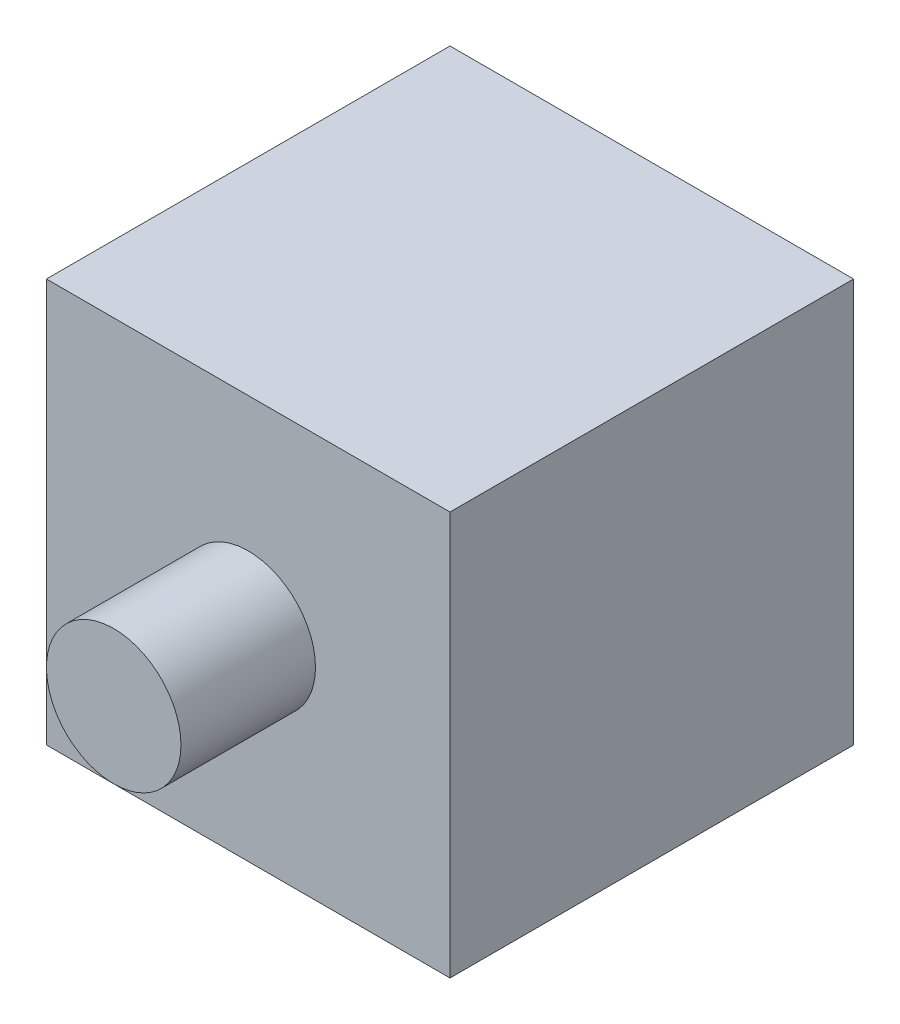
from build123d import *

# Parameters (mm, degrees)
SKETCH1_W           = 30
SKETCH1_H           = 30
BOSS_EXTRUDE1_DEPTH = 30
SKETCH2_R           = 5
BOSS_EXTRUDE2_DEPTH = 10


with BuildPart() as part:
    # Sketch1 → Boss-Extrude1 (new body)
    with BuildSketch(Plane(origin=(0, 0, 0), x_dir=(1, 0, 0), z_dir=(0, 1, 0))):
        Rectangle(SKETCH1_W, SKETCH1_H)
    extrude(amount=BOSS_EXTRUDE1_DEPTH)

    # Sketch2 → Boss-Extrude2 (add)
    with BuildSketch(Plane.XY.offset(15)):
        with Locations((0, 15)):
            Circle(SKETCH2_R)
    extrude(amount=BOSS_EXTRUDE2_DEPTH)


solid = part.part
